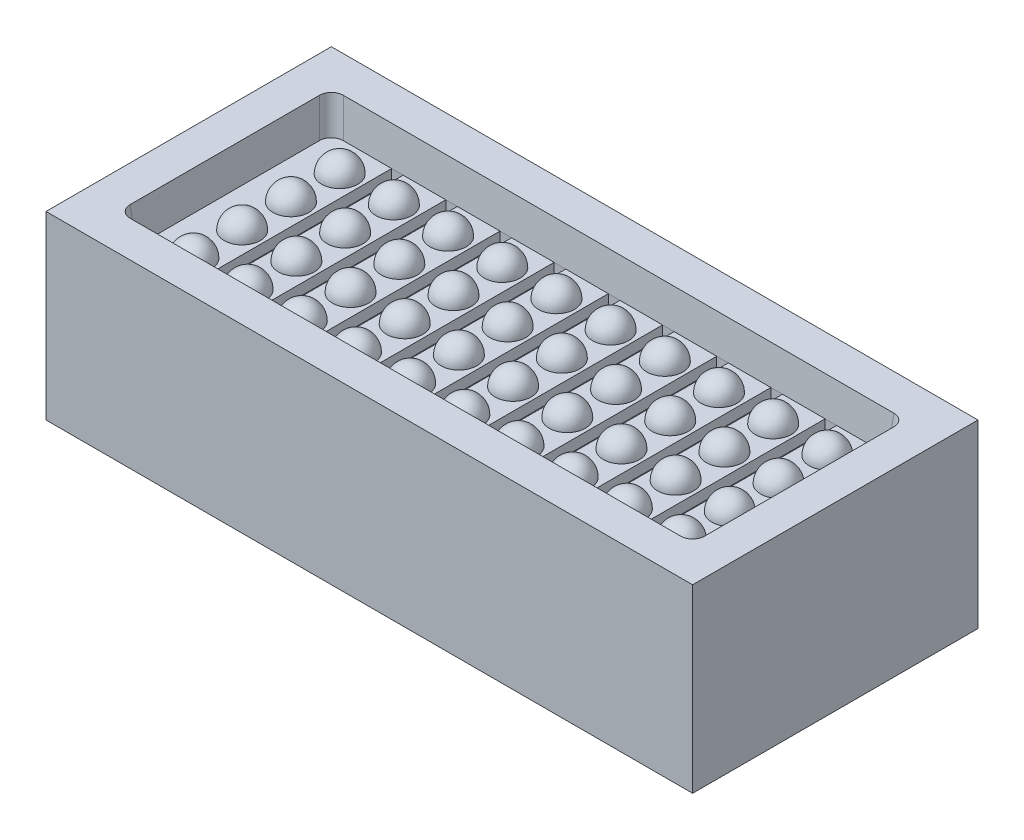
from build123d import *

# Parameters (mm, degrees)
SKETCH1_W           = 179
SKETCH1_H           = 79
BOSS_EXTRUDE2_DEPTH = 50
SKETCH2_W           = 159
SKETCH2_H           = 59
CUT_EXTRUDE1_DEPTH  = 10
CUT_EXTRUDE1_DRAFT  = -5
FILLET1_R           = 3.3
LPATTERN1_COUNT     = 10
LPATTERN1_PITCH     = 15
LPATTERN2_COUNT     = 4
LPATTERN2_PITCH     = 13.5
SKETCH5_W           = 3.2
SKETCH5_H           = 57.25022673
CUT_EXTRUDE3_DEPTH  = 3


with BuildPart() as part:
    # Sketch1 → Boss-Extrude2 (new body)
    with BuildSketch(Plane(origin=(0, 0, 0), x_dir=(1, 0, 0), z_dir=(0, 1, 0))):
        with Locations((-89.5, 39.5)):
            Rectangle(SKETCH1_W, SKETCH1_H)
    extrude(amount=BOSS_EXTRUDE2_DEPTH)


with BuildPart() as cut_extrude1_tool:
    # Sketch2 → Cut-Extrude1 (with draft: the straight prism first)
    with BuildSketch(Plane(origin=(0, 50, 0), x_dir=(1, 0, 0), z_dir=(0, 1, 0))):
        with Locations((-89.5, 39.5)):
            Rectangle(SKETCH2_W, SKETCH2_H)
    extrude(amount=-CUT_EXTRUDE1_DEPTH)
    # Cut-Extrude1: the draft: its side faces are tilted about the plane it starts from
    cut_extrude1_sides = [cut_extrude1_tool.faces().sort_by_distance(p)[0] for p in [
        (-169, 45, -39.5),
        (-89.5, 45, -10),
        (-10, 45, -39.5),
        (-89.5, 45, -69),
    ]]
    draft(cut_extrude1_sides, Plane(origin=(0, 50, 0), x_dir=(1, 0, 0), z_dir=(0, 1, 0)), CUT_EXTRUDE1_DRAFT)


with BuildPart() as part_1:
    add(part.part)

    # Cut-Extrude1: cut by cut_extrude1_tool
    add(cut_extrude1_tool.part, mode=Mode.SUBTRACT)

    # Fillet1
    fillet1_edges = [part_1.edges().sort_by_distance(p)[0] for p in [
        (-168.562556682, 45, -10.437443318),
        (-168.562556682, 45, -68.562556682),
        (-10.437443318, 45, -68.562556682),
        (-10.437443318, 45, -10.437443318),
    ]]
    fillet(fillet1_edges, radius=FILLET1_R)

    # Sketch3 → Revolve2 (revolve)
    with BuildSketch(Plane(origin=(0, 40, 0), x_dir=(1, 0, 0), z_dir=(0, 1, 0))):
        with BuildLine():
            Line((-157.348828554, 64.653025264), (-157.348828554, 54.653025264))
            ThreePointArc((-157.348828554, 54.653025264), (-152.348828554, 59.653025264), (-157.348828554, 64.653025264))
        make_face()
    revolve2 = revolve(axis=Axis((-157.348828554, 40, -64.653025264), (0, 0, 1)))

    # LPattern1: Revolve2 ×10
    with Locations(*[(i * LPATTERN1_PITCH, 0, 0) for i in range(1, LPATTERN1_COUNT)]):
        add(revolve2)

    # LPattern2: Revolve2 ×4
    with Locations(*[(0, 0, i * LPATTERN2_PITCH) for i in range(1, LPATTERN2_COUNT)]):
        add(revolve2)

    # LPattern2 copy 1 sketch → LPattern2 copy 1 (revolve)
    with BuildSketch(Plane(origin=(15, 40, 13.5), x_dir=(1, 0, 0), z_dir=(0, 1, 0))):
        with BuildLine():
            Line((-157.348828554, 64.653025264), (-157.348828554, 54.653025264))
            ThreePointArc((-157.348828554, 54.653025264), (-152.348828554, 59.653025264), (-157.348828554, 64.653025264))
        make_face()
    revolve(axis=Axis((-142.348828554, 40, -51.153025264), (0, 0, 1)))

    # LPattern2 copy 2 sketch → LPattern2 copy 2 (revolve)
    with BuildSketch(Plane(origin=(15, 40, 27), x_dir=(1, 0, 0), z_dir=(0, 1, 0))):
        with BuildLine():
            Line((-157.348828554, 64.653025264), (-157.348828554, 54.653025264))
            ThreePointArc((-157.348828554, 54.653025264), (-152.348828554, 59.653025264), (-157.348828554, 64.653025264))
        make_face()
    revolve(axis=Axis((-142.348828554, 40, -37.653025264), (0, 0, 1)))

    # LPattern2 copy 3 sketch → LPattern2 copy 3 (revolve)
    with BuildSketch(Plane(origin=(15, 40, 40.5), x_dir=(1, 0, 0), z_dir=(0, 1, 0))):
        with BuildLine():
            Line((-157.348828554, 64.653025264), (-157.348828554, 54.653025264))
            ThreePointArc((-157.348828554, 54.653025264), (-152.348828554, 59.653025264), (-157.348828554, 64.653025264))
        make_face()
    revolve(axis=Axis((-142.348828554, 40, -24.153025264), (0, 0, 1)))

    # LPattern2 copy 4 sketch → LPattern2 copy 4 (revolve)
    with BuildSketch(Plane(origin=(30, 40, 13.5), x_dir=(1, 0, 0), z_dir=(0, 1, 0))):
        with BuildLine():
            Line((-157.348828554, 64.653025264), (-157.348828554, 54.653025264))
            ThreePointArc((-157.348828554, 54.653025264), (-152.348828554, 59.653025264), (-157.348828554, 64.653025264))
        make_face()
    revolve(axis=Axis((-127.348828554, 40, -51.153025264), (0, 0, 1)))

    # LPattern2 copy 5 sketch → LPattern2 copy 5 (revolve)
    with BuildSketch(Plane(origin=(30, 40, 27), x_dir=(1, 0, 0), z_dir=(0, 1, 0))):
        with BuildLine():
            Line((-157.348828554, 64.653025264), (-157.348828554, 54.653025264))
            ThreePointArc((-157.348828554, 54.653025264), (-152.348828554, 59.653025264), (-157.348828554, 64.653025264))
        make_face()
    revolve(axis=Axis((-127.348828554, 40, -37.653025264), (0, 0, 1)))

    # LPattern2 copy 6 sketch → LPattern2 copy 6 (revolve)
    with BuildSketch(Plane(origin=(30, 40, 40.5), x_dir=(1, 0, 0), z_dir=(0, 1, 0))):
        with BuildLine():
            Line((-157.348828554, 64.653025264), (-157.348828554, 54.653025264))
            ThreePointArc((-157.348828554, 54.653025264), (-152.348828554, 59.653025264), (-157.348828554, 64.653025264))
        make_face()
    revolve(axis=Axis((-127.348828554, 40, -24.153025264), (0, 0, 1)))

    # LPattern2 copy 7 sketch → LPattern2 copy 7 (revolve)
    with BuildSketch(Plane(origin=(45, 40, 13.5), x_dir=(1, 0, 0), z_dir=(0, 1, 0))):
        with BuildLine():
            Line((-157.348828554, 64.653025264), (-157.348828554, 54.653025264))
            ThreePointArc((-157.348828554, 54.653025264), (-152.348828554, 59.653025264), (-157.348828554, 64.653025264))
        make_face()
    revolve(axis=Axis((-112.348828554, 40, -51.153025264), (0, 0, 1)))

    # LPattern2 copy 8 sketch → LPattern2 copy 8 (revolve)
    with BuildSketch(Plane(origin=(45, 40, 27), x_dir=(1, 0, 0), z_dir=(0, 1, 0))):
        with BuildLine():
            Line((-157.348828554, 64.653025264), (-157.348828554, 54.653025264))
            ThreePointArc((-157.348828554, 54.653025264), (-152.348828554, 59.653025264), (-157.348828554, 64.653025264))
        make_face()
    revolve(axis=Axis((-112.348828554, 40, -37.653025264), (0, 0, 1)))

    # LPattern2 copy 9 sketch → LPattern2 copy 9 (revolve)
    with BuildSketch(Plane(origin=(45, 40, 40.5), x_dir=(1, 0, 0), z_dir=(0, 1, 0))):
        with BuildLine():
            Line((-157.348828554, 64.653025264), (-157.348828554, 54.653025264))
            ThreePointArc((-157.348828554, 54.653025264), (-152.348828554, 59.653025264), (-157.348828554, 64.653025264))
        make_face()
    revolve(axis=Axis((-112.348828554, 40, -24.153025264), (0, 0, 1)))

    # LPattern2 copy 10 sketch → LPattern2 copy 10 (revolve)
    with BuildSketch(Plane(origin=(60, 40, 13.5), x_dir=(1, 0, 0), z_dir=(0, 1, 0))):
        with BuildLine():
            Line((-157.348828554, 64.653025264), (-157.348828554, 54.653025264))
            ThreePointArc((-157.348828554, 54.653025264), (-152.348828554, 59.653025264), (-157.348828554, 64.653025264))
        make_face()
    revolve(axis=Axis((-97.348828554, 40, -51.153025264), (0, 0, 1)))

    # LPattern2 copy 11 sketch → LPattern2 copy 11 (revolve)
    with BuildSketch(Plane(origin=(60, 40, 27), x_dir=(1, 0, 0), z_dir=(0, 1, 0))):
        with BuildLine():
            Line((-157.348828554, 64.653025264), (-157.348828554, 54.653025264))
            ThreePointArc((-157.348828554, 54.653025264), (-152.348828554, 59.653025264), (-157.348828554, 64.653025264))
        make_face()
    revolve(axis=Axis((-97.348828554, 40, -37.653025264), (0, 0, 1)))

    # LPattern2 copy 12 sketch → LPattern2 copy 12 (revolve)
    with BuildSketch(Plane(origin=(60, 40, 40.5), x_dir=(1, 0, 0), z_dir=(0, 1, 0))):
        with BuildLine():
            Line((-157.348828554, 64.653025264), (-157.348828554, 54.653025264))
            ThreePointArc((-157.348828554, 54.653025264), (-152.348828554, 59.653025264), (-157.348828554, 64.653025264))
        make_face()
    revolve(axis=Axis((-97.348828554, 40, -24.153025264), (0, 0, 1)))

    # LPattern2 copy 13 sketch → LPattern2 copy 13 (revolve)
    with BuildSketch(Plane(origin=(75, 40, 13.5), x_dir=(1, 0, 0), z_dir=(0, 1, 0))):
        with BuildLine():
            Line((-157.348828554, 64.653025264), (-157.348828554, 54.653025264))
            ThreePointArc((-157.348828554, 54.653025264), (-152.348828554, 59.653025264), (-157.348828554, 64.653025264))
        make_face()
    revolve(axis=Axis((-82.348828554, 40, -51.153025264), (0, 0, 1)))

    # LPattern2 copy 14 sketch → LPattern2 copy 14 (revolve)
    with BuildSketch(Plane(origin=(75, 40, 27), x_dir=(1, 0, 0), z_dir=(0, 1, 0))):
        with BuildLine():
            Line((-157.348828554, 64.653025264), (-157.348828554, 54.653025264))
            ThreePointArc((-157.348828554, 54.653025264), (-152.348828554, 59.653025264), (-157.348828554, 64.653025264))
        make_face()
    revolve(axis=Axis((-82.348828554, 40, -37.653025264), (0, 0, 1)))

    # LPattern2 copy 15 sketch → LPattern2 copy 15 (revolve)
    with BuildSketch(Plane(origin=(75, 40, 40.5), x_dir=(1, 0, 0), z_dir=(0, 1, 0))):
        with BuildLine():
            Line((-157.348828554, 64.653025264), (-157.348828554, 54.653025264))
            ThreePointArc((-157.348828554, 54.653025264), (-152.348828554, 59.653025264), (-157.348828554, 64.653025264))
        make_face()
    revolve(axis=Axis((-82.348828554, 40, -24.153025264), (0, 0, 1)))

    # LPattern2 copy 16 sketch → LPattern2 copy 16 (revolve)
    with BuildSketch(Plane(origin=(90, 40, 13.5), x_dir=(1, 0, 0), z_dir=(0, 1, 0))):
        with BuildLine():
            Line((-157.348828554, 64.653025264), (-157.348828554, 54.653025264))
            ThreePointArc((-157.348828554, 54.653025264), (-152.348828554, 59.653025264), (-157.348828554, 64.653025264))
        make_face()
    revolve(axis=Axis((-67.348828554, 40, -51.153025264), (0, 0, 1)))

    # LPattern2 copy 17 sketch → LPattern2 copy 17 (revolve)
    with BuildSketch(Plane(origin=(90, 40, 27), x_dir=(1, 0, 0), z_dir=(0, 1, 0))):
        with BuildLine():
            Line((-157.348828554, 64.653025264), (-157.348828554, 54.653025264))
            ThreePointArc((-157.348828554, 54.653025264), (-152.348828554, 59.653025264), (-157.348828554, 64.653025264))
        make_face()
    revolve(axis=Axis((-67.348828554, 40, -37.653025264), (0, 0, 1)))

    # LPattern2 copy 18 sketch → LPattern2 copy 18 (revolve)
    with BuildSketch(Plane(origin=(90, 40, 40.5), x_dir=(1, 0, 0), z_dir=(0, 1, 0))):
        with BuildLine():
            Line((-157.348828554, 64.653025264), (-157.348828554, 54.653025264))
            ThreePointArc((-157.348828554, 54.653025264), (-152.348828554, 59.653025264), (-157.348828554, 64.653025264))
        make_face()
    revolve(axis=Axis((-67.348828554, 40, -24.153025264), (0, 0, 1)))

    # LPattern2 copy 19 sketch → LPattern2 copy 19 (revolve)
    with BuildSketch(Plane(origin=(105, 40, 13.5), x_dir=(1, 0, 0), z_dir=(0, 1, 0))):
        with BuildLine():
            Line((-157.348828554, 64.653025264), (-157.348828554, 54.653025264))
            ThreePointArc((-157.348828554, 54.653025264), (-152.348828554, 59.653025264), (-157.348828554, 64.653025264))
        make_face()
    revolve(axis=Axis((-52.348828554, 40, -51.153025264), (0, 0, 1)))

    # LPattern2 copy 20 sketch → LPattern2 copy 20 (revolve)
    with BuildSketch(Plane(origin=(105, 40, 27), x_dir=(1, 0, 0), z_dir=(0, 1, 0))):
        with BuildLine():
            Line((-157.348828554, 64.653025264), (-157.348828554, 54.653025264))
            ThreePointArc((-157.348828554, 54.653025264), (-152.348828554, 59.653025264), (-157.348828554, 64.653025264))
        make_face()
    revolve(axis=Axis((-52.348828554, 40, -37.653025264), (0, 0, 1)))

    # LPattern2 copy 21 sketch → LPattern2 copy 21 (revolve)
    with BuildSketch(Plane(origin=(105, 40, 40.5), x_dir=(1, 0, 0), z_dir=(0, 1, 0))):
        with BuildLine():
            Line((-157.348828554, 64.653025264), (-157.348828554, 54.653025264))
            ThreePointArc((-157.348828554, 54.653025264), (-152.348828554, 59.653025264), (-157.348828554, 64.653025264))
        make_face()
    revolve(axis=Axis((-52.348828554, 40, -24.153025264), (0, 0, 1)))

    # LPattern2 copy 22 sketch → LPattern2 copy 22 (revolve)
    with BuildSketch(Plane(origin=(120, 40, 13.5), x_dir=(1, 0, 0), z_dir=(0, 1, 0))):
        with BuildLine():
            Line((-157.348828554, 64.653025264), (-157.348828554, 54.653025264))
            ThreePointArc((-157.348828554, 54.653025264), (-152.348828554, 59.653025264), (-157.348828554, 64.653025264))
        make_face()
    revolve(axis=Axis((-37.348828554, 40, -51.153025264), (0, 0, 1)))

    # LPattern2 copy 23 sketch → LPattern2 copy 23 (revolve)
    with BuildSketch(Plane(origin=(120, 40, 27), x_dir=(1, 0, 0), z_dir=(0, 1, 0))):
        with BuildLine():
            Line((-157.348828554, 64.653025264), (-157.348828554, 54.653025264))
            ThreePointArc((-157.348828554, 54.653025264), (-152.348828554, 59.653025264), (-157.348828554, 64.653025264))
        make_face()
    revolve(axis=Axis((-37.348828554, 40, -37.653025264), (0, 0, 1)))

    # LPattern2 copy 24 sketch → LPattern2 copy 24 (revolve)
    with BuildSketch(Plane(origin=(120, 40, 40.5), x_dir=(1, 0, 0), z_dir=(0, 1, 0))):
        with BuildLine():
            Line((-157.348828554, 64.653025264), (-157.348828554, 54.653025264))
            ThreePointArc((-157.348828554, 54.653025264), (-152.348828554, 59.653025264), (-157.348828554, 64.653025264))
        make_face()
    revolve(axis=Axis((-37.348828554, 40, -24.153025264), (0, 0, 1)))

    # LPattern2 copy 25 sketch → LPattern2 copy 25 (revolve)
    with BuildSketch(Plane(origin=(135, 40, 13.5), x_dir=(1, 0, 0), z_dir=(0, 1, 0))):
        with BuildLine():
            Line((-157.348828554, 64.653025264), (-157.348828554, 54.653025264))
            ThreePointArc((-157.348828554, 54.653025264), (-152.348828554, 59.653025264), (-157.348828554, 64.653025264))
        make_face()
    revolve(axis=Axis((-22.348828554, 40, -51.153025264), (0, 0, 1)))

    # LPattern2 copy 26 sketch → LPattern2 copy 26 (revolve)
    with BuildSketch(Plane(origin=(135, 40, 27), x_dir=(1, 0, 0), z_dir=(0, 1, 0))):
        with BuildLine():
            Line((-157.348828554, 64.653025264), (-157.348828554, 54.653025264))
            ThreePointArc((-157.348828554, 54.653025264), (-152.348828554, 59.653025264), (-157.348828554, 64.653025264))
        make_face()
    revolve(axis=Axis((-22.348828554, 40, -37.653025264), (0, 0, 1)))

    # LPattern2 copy 27 sketch → LPattern2 copy 27 (revolve)
    with BuildSketch(Plane(origin=(135, 40, 40.5), x_dir=(1, 0, 0), z_dir=(0, 1, 0))):
        with BuildLine():
            Line((-157.348828554, 64.653025264), (-157.348828554, 54.653025264))
            ThreePointArc((-157.348828554, 54.653025264), (-152.348828554, 59.653025264), (-157.348828554, 64.653025264))
        make_face()
    revolve(axis=Axis((-22.348828554, 40, -24.153025264), (0, 0, 1)))

    # Sketch5 → Cut-Extrude3 (cut)
    with BuildSketch(Plane(origin=(0, 40, 0), x_dir=(1, 0, 0), z_dir=(0, 1, 0))):
        with Locations((-119.848828554, 39.5)):
            Rectangle(SKETCH5_W, SKETCH5_H)
        with Locations((-89.848828554, 39.5)):
            Rectangle(SKETCH5_W, SKETCH5_H)
        with Locations((-74.848828554, 39.5)):
            Rectangle(SKETCH5_W, SKETCH5_H)
        with Locations((-59.848828554, 39.5)):
            Rectangle(SKETCH5_W, SKETCH5_H)
        with Locations((-29.848828554, 39.5)):
            Rectangle(SKETCH5_W, SKETCH5_H)
        with Locations((-134.848828554, 39.5)):
            Rectangle(SKETCH5_W, SKETCH5_H)
        with Locations((-149.848828554, 39.5)):
            Rectangle(SKETCH5_W, SKETCH5_H)
        with Locations((-104.848828554, 39.5)):
            Rectangle(SKETCH5_W, SKETCH5_H)
        with Locations((-44.848828554, 39.5)):
            Rectangle(SKETCH5_W, SKETCH5_H)
    extrude(amount=-CUT_EXTRUDE3_DEPTH, mode=Mode.SUBTRACT)


solid = part_1.part
